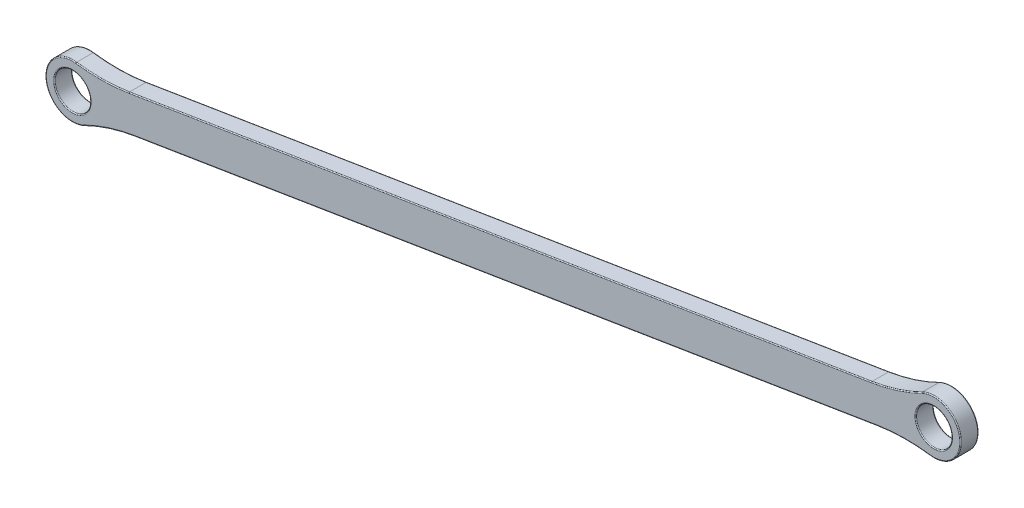
from build123d import *

# Parameters (mm, degrees)
BOSS_EXTRUDE1_DEPTH = 3
FILLET1_R           = 30
FILLET2_R           = 0.15


with BuildPart() as part:
    # Sketch1 → Boss-Extrude1 (new body)
    with BuildSketch(Plane.XY):
        with BuildLine():
            ThreePointArc((-230.422405518, 199.945444308), (-233.864456933, 202.425823726), (-231.384077516, 205.867875141))
            Line((-231.384077516, 205.867875141), (-228.073338032, 206.405466131))
            ThreePointArc((-228.073338032, 206.405466131), (-235.345064641, 202.185405726), (-227.111666035, 200.483035298))
            Line((-227.111666035, 200.483035298), (-230.422405518, 199.945444308))
        make_face()
        with BuildLine():
            Line((-228.073338032, 206.405466131), (-231.384077516, 205.867875141))
            ThreePointArc((-231.384077516, 205.867875141), (-227.942026101, 203.387495723), (-230.422405518, 199.945444308))
            Line((-230.422405518, 199.945444308), (-227.111666035, 200.483035298))
            ThreePointArc((-227.111666035, 200.483035298), (-226.583977131, 201.644140352), (-226.403241517, 202.906659725))
            ThreePointArc((-226.403241517, 202.906659725), (-226.842172342, 204.845142936), (-228.073338032, 206.405466131))
        make_face()
        with BuildLine():
            Line((-90.582333401, 228.730969425), (-228.073338032, 206.405466131))
            ThreePointArc((-228.073338032, 206.405466131), (-226.842172342, 204.845142936), (-226.403241517, 202.906659725))
            ThreePointArc((-226.403241517, 202.906659725), (-226.583977131, 201.644140352), (-227.111666035, 200.483035298))
            Line((-227.111666035, 200.483035298), (-89.620661404, 222.808538592))
            ThreePointArc((-89.620661404, 222.808538592), (-91.232581044, 225.586091), (-90.582333401, 228.730969425))
        make_face()
        with BuildLine():
            Line((-87.271593918, 229.268560415), (-90.582333401, 228.730969425))
            ThreePointArc((-90.582333401, 228.730969425), (-91.232581044, 225.586091), (-89.620661404, 222.808538592))
            Line((-89.620661404, 222.808538592), (-86.30992192, 223.346129582))
            ThreePointArc((-86.30992192, 223.346129582), (-89.751973336, 225.826508999), (-87.271593918, 229.268560415))
        make_face()
        with BuildLine():
            ThreePointArc((-82.290757919, 226.307344998), (-85.528238547, 230.626609384), (-90.582333401, 228.730969425))
            Line((-90.582333401, 228.730969425), (-87.271593918, 229.268560415))
            ThreePointArc((-87.271593918, 229.268560415), (-83.829542503, 226.788180997), (-86.30992192, 223.346129582))
            Line((-86.30992192, 223.346129582), (-89.620661404, 222.808538592))
            ThreePointArc((-89.620661404, 222.808538592), (-84.852274708, 222.246275824), (-82.290757919, 226.307344998))
        make_face()
    extrude(amount=-BOSS_EXTRUDE1_DEPTH)

    # Fillet1
    fillet1_edges = [part.edges().sort_by_distance(p)[0] for p in [
        (-228.073338032, 206.405466131, -1.5),
        (-90.582333401, 228.730969425, -1.5),
        (-89.620661404, 222.808538592, -1.5),
        (-227.111666035, 200.483035298, -1.5),
    ]]
    fillet(fillet1_edges, radius=FILLET1_R)

    # Fillet2
    fillet2_edges = [part.edges().sort_by_distance(p)[0] for p in [
        (-87.271593918, 229.268560415, 0),
        (-82.348934795, 227.028598996, 0),
        (-82.348934795, 227.028598996, -3),
        (-159.327835717, 217.568217778, 0),
        (-159.327835717, 217.568217778, -3),
        (-158.366163719, 211.645786945, 0),
        (-158.366163719, 211.645786945, -3),
        (-235.345064641, 202.185405726, 0),
        (-235.345064641, 202.185405726, -3),
        (-92.890290393, 228.688381266, 0),
        (-92.890290393, 228.688381266, -3),
        (-91.823514475, 222.118670798, 0),
        (-230.422405518, 199.945444308, -3),
        (-91.823514475, 222.118670798, -3),
        (-224.803709043, 200.525623457, 0),
        (-224.803709043, 200.525623457, -3),
        (-225.870484961, 207.095333925, 0),
        (-225.870484961, 207.095333925, -3),
        (-87.271593918, 229.268560415, -3),
        (-230.422405518, 199.945444308, 0),
    ]]
    fillet(fillet2_edges, radius=FILLET2_R)


solid = part.part
